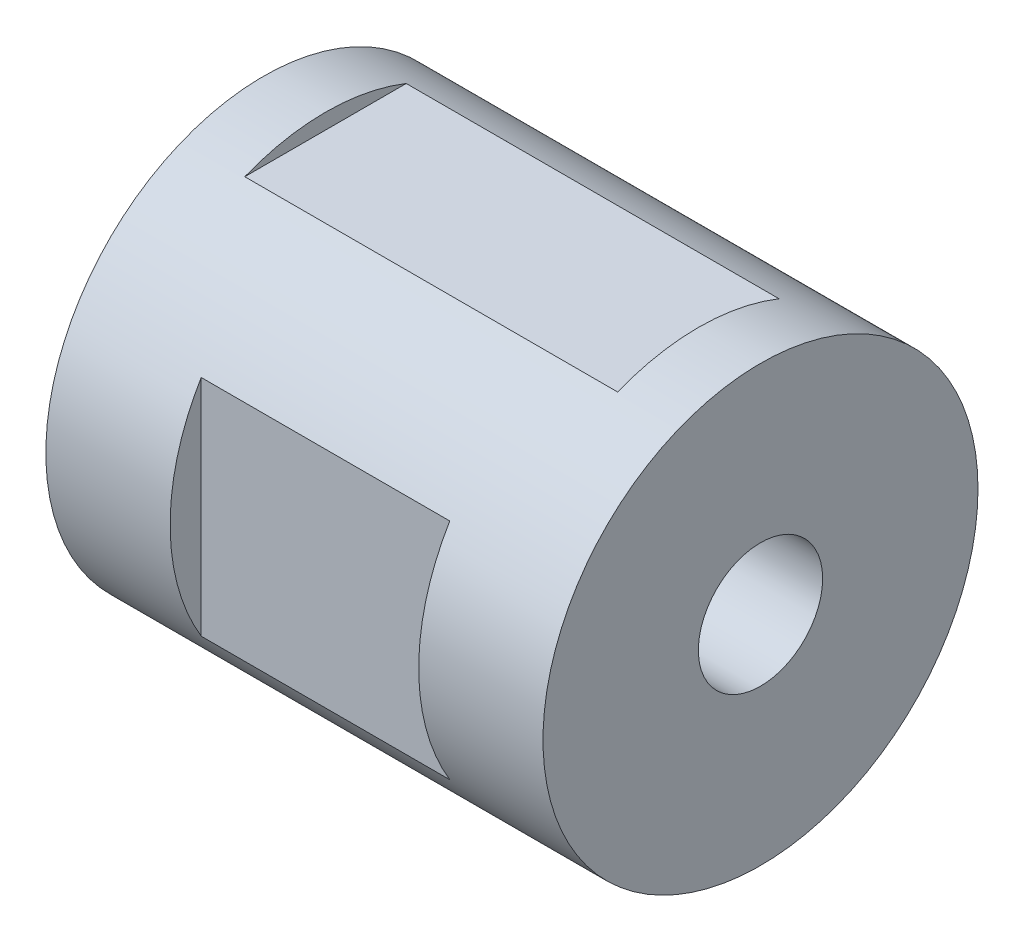
from build123d import *

# Parameters (mm, degrees)
SKETCH5_R           = 35
SKETCH5_R_2         = 10
BOSS_EXTRUDE2_DEPTH = 80
SKETCH6_W           = 60
SKETCH6_H           = 25.98
CUT_EXTRUDE3_DEPTH  = 10
SKETCH7_W           = 40
SKETCH7_H           = 36.06
CUT_EXTRUDE4_DEPTH  = 10


with BuildPart() as part:
    # Sketch5 → Boss-Extrude2 (new body)
    with BuildSketch(Plane(origin=(0, 0, 0), x_dir=(0, 0, -1), z_dir=(1, 0, 0))):
        Circle(SKETCH5_R)
        Circle(SKETCH5_R_2, mode=Mode.SUBTRACT)
    extrude(amount=-BOSS_EXTRUDE2_DEPTH)

    # Sketch6 → Cut-Extrude3 (cut)
    with BuildSketch(Plane(origin=(0, 32.5, 0), x_dir=(1, 0, 0), z_dir=(0, 1, 0))):
        with Locations((-40, 0)):
            Rectangle(SKETCH6_W, SKETCH6_H)
    extrude(amount=CUT_EXTRUDE3_DEPTH, mode=Mode.SUBTRACT)

    # Sketch7 → Cut-Extrude4 (cut)
    with BuildSketch(Plane.XY.offset(30)):
        with Locations((-40, 0)):
            Rectangle(SKETCH7_W, SKETCH7_H)
    extrude(amount=CUT_EXTRUDE4_DEPTH, mode=Mode.SUBTRACT)


solid = part.part
